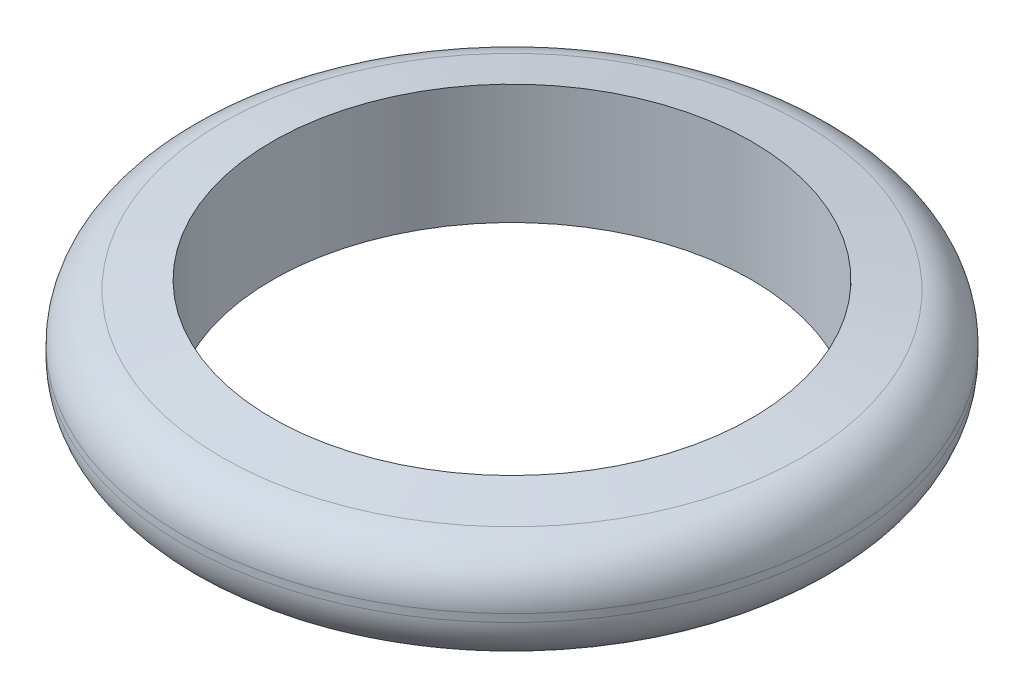
from build123d import *

# Parameters (mm, degrees)
FILLET1_R = 8


with BuildPart() as part:
    # Sketch2 → Revolve1 (revolve)
    with BuildSketch(Plane.XY):
        Polygon((40, -10), (40, 10), (55, 7.355095289), (55, -7.355095289), align=None)
    revolve(axis=Axis((0, 0, 0), (0, 1, 0)))

    # Fillet1
    fillet1_edges = [part.edges().sort_by_distance(p)[0] for p in [
        (-55, -7.355095289, 0),
        (-55, 7.355095289, 0),
    ]]
    fillet(fillet1_edges, radius=FILLET1_R)


solid = part.part
